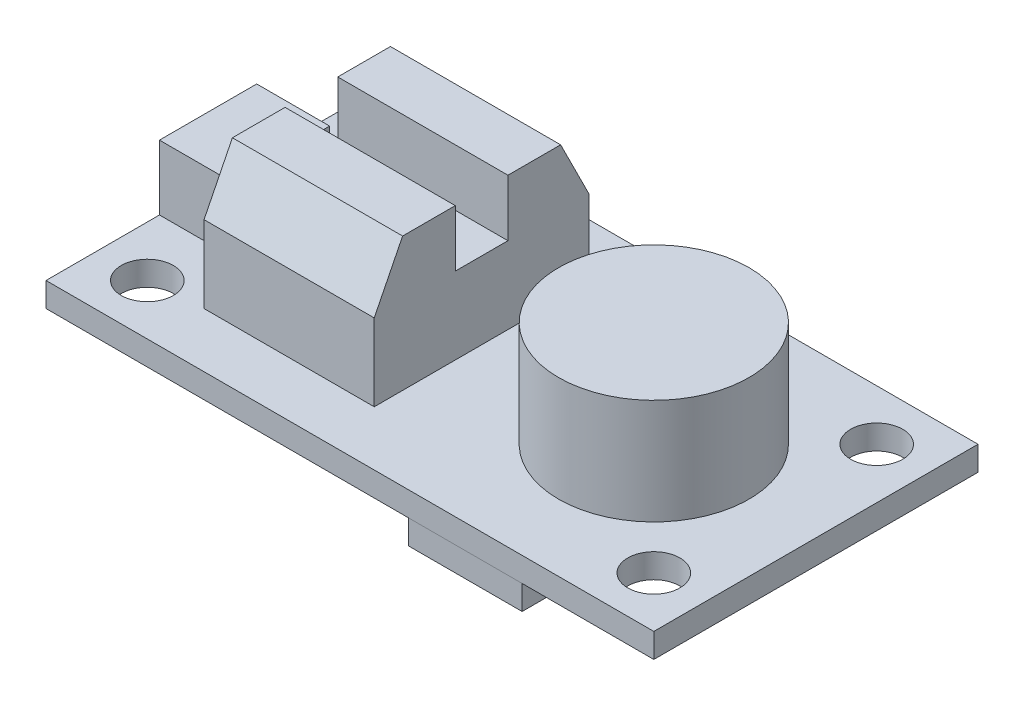
from build123d import *

# Parameters (mm, degrees)
SKETCH1_W               = 38.1
SKETCH1_H               = 20.32
BOSS_EXTRUDE1_DEPTH     = 1.524
F_4_CLEARANCE_HOLE1_D   = 3.2639
SKETCH4_W               = 4.572
SKETCH4_H               = 6.096
BOSS_EXTRUDE2_DEPTH     = 4.064
SKETCH5_R               = 5.969
BOSS_EXTRUDE3_DEPTH     = 6.604
SKETCH6_W               = 10.668
SKETCH6_H               = 13.462
BOSS_EXTRUDE4_DEPTH     = 4.826
BOSS_EXTRUDE5_DEPTH     = 10.668
SKETCH8_W               = 7.874
SKETCH8_H               = 5.588
BOSS_EXTRUDE6_DEPTH     = 3.048
SKETCH9_W               = 7.112
SKETCH9_H               = 5.08
BOSS_EXTRUDE7_DEPTH     = 1.524
SKETCH10_W              = 2.54
SKETCH10_H              = 4.064
BOSS_EXTRUDE8_DEPTH     = 1.016
SKETCH11_W              = 5.08
SKETCH11_H              = 5.08
BOSS_EXTRUDE9_DEPTH     = 1.016
SKETCH12_W              = 4.064
SKETCH12_H              = 2.032
BOSS_EXTRUDE10_DEPTH    = 1.016
SKETCH13_W              = 3.048
SKETCH13_H              = 3.048
BOSS_EXTRUDE11_DEPTH    = 0.508
SKETCH14_W              = 3.048
SKETCH14_H              = 3.556
BOSS_EXTRUDE12_DEPTH    = 1.016
SKETCH15_W              = 2.032
SKETCH15_H              = 4.064
BOSS_EXTRUDE13_DEPTH    = 1.524
SKETCH16_W              = 3.048
SKETCH16_H              = 3.048
BOSS_EXTRUDE14_DEPTH    = 1.016
SKETCH17_R              = 0.508
BOSS_EXTRUDE15_DEPTH    = 1.524
LPATTERN1_COUNT         = 4
LPATTERN1_PITCH         = 2.794
MIRROR1_COPY_1_SKETCH_R = 0.508
MIRROR1_COPY_1_DEPTH    = 1.524
MIRROR1_COPY_2_SKETCH_R = 0.508
MIRROR1_COPY_2_DEPTH    = 1.524
MIRROR1_COPY_3_SKETCH_R = 0.508
MIRROR1_COPY_3_DEPTH    = 1.524


with BuildPart() as part:
    # Sketch1 → Boss-Extrude1 (new body)
    with BuildSketch(Plane(origin=(0, 0, 0), x_dir=(1, 0, 0), z_dir=(0, 1, 0))):
        Rectangle(SKETCH1_W, SKETCH1_H)
    extrude(amount=BOSS_EXTRUDE1_DEPTH)

    # #4 Clearance Hole1 (through all)
    with Locations(Plane(origin=(0, 1.524, 0), x_dir=(1, 0, 0), z_dir=(0, 1, 0))):
        with Locations((-15.875, 6.985), (15.875, -6.985), (-15.875, -6.985), (15.875, 6.985)):
            Hole(F_4_CLEARANCE_HOLE1_D / 2)

    # Sketch4 → Boss-Extrude2 (add)
    with BuildSketch(Plane(origin=(0, 1.524, 0), x_dir=(1, 0, 0), z_dir=(0, 1, 0))):
        with Locations((-16.764, 0)):
            Rectangle(SKETCH4_W, SKETCH4_H)
    extrude(amount=BOSS_EXTRUDE2_DEPTH)

    # Sketch5 → Boss-Extrude3 (add)
    with BuildSketch(Plane(origin=(0, 1.524, 0), x_dir=(1, 0, 0), z_dir=(0, 1, 0))):
        with Locations((8.89, 0)):
            Circle(SKETCH5_R)
    extrude(amount=BOSS_EXTRUDE3_DEPTH)

    # Sketch6 → Boss-Extrude4 (add)
    with BuildSketch(Plane(origin=(0, 1.524, 0), x_dir=(1, 0, 0), z_dir=(0, 1, 0))):
        with Locations((-7.239, 0)):
            Rectangle(SKETCH6_W, SKETCH6_H)
    extrude(amount=BOSS_EXTRUDE4_DEPTH)

    # Sketch7 → Boss-Extrude5 (add)
    with BuildSketch(Plane.ZY.offset(12.573)):
        Polygon((-6.731, 6.35), (-4.953, 9.906), (-1.651, 9.906), (-1.651, 6.35), align=None)
        Polygon((6.731, 6.35), (4.953, 9.906), (1.651, 9.906), (1.651, 6.35), align=None)
    extrude(amount=-BOSS_EXTRUDE5_DEPTH)

    # Sketch8 → Boss-Extrude6 (add)
    with BuildSketch(Plane.XZ):
        with Locations((7.239, -7.366)):
            Rectangle(SKETCH8_W, SKETCH8_H)
    extrude(amount=BOSS_EXTRUDE6_DEPTH)

    # Sketch9 → Boss-Extrude7 (add)
    with BuildSketch(Plane.XZ):
        with Locations((7.239, 7.62)):
            Rectangle(SKETCH9_W, SKETCH9_H)
    extrude(amount=BOSS_EXTRUDE7_DEPTH)

    # Sketch10 → Boss-Extrude8 (add)
    with BuildSketch(Plane.XZ):
        with Locations((13.589, 0)):
            Rectangle(SKETCH10_W, SKETCH10_H)
    extrude(amount=BOSS_EXTRUDE8_DEPTH)

    # Sketch11 → Boss-Extrude9 (add)
    with BuildSketch(Plane.XZ):
        with Locations((4.191, 0)):
            Rectangle(SKETCH11_W, SKETCH11_H)
    extrude(amount=BOSS_EXTRUDE9_DEPTH)

    # Sketch12 → Boss-Extrude10 (add)
    with BuildSketch(Plane.XZ):
        with Locations((-2.413, 7.112)):
            Rectangle(SKETCH12_W, SKETCH12_H)
    extrude(amount=BOSS_EXTRUDE10_DEPTH)

    # Sketch13 → Boss-Extrude11 (add)
    with BuildSketch(Plane.XZ):
        with Locations((-3.81, -6.096)):
            Rectangle(SKETCH13_W, SKETCH13_H)
    extrude(amount=BOSS_EXTRUDE11_DEPTH)

    # Sketch14 → Boss-Extrude12 (add)
    with BuildSketch(Plane.XZ):
        with Locations((-9.906, -6.35)):
            Rectangle(SKETCH14_W, SKETCH14_H)
    extrude(amount=BOSS_EXTRUDE12_DEPTH)

    # Sketch15 → Boss-Extrude13 (add)
    with BuildSketch(Plane.XZ):
        with Locations((-15.494, 1.27)):
            Rectangle(SKETCH15_W, SKETCH15_H)
    extrude(amount=BOSS_EXTRUDE13_DEPTH)

    # Sketch16 → Boss-Extrude14 (add)
    with BuildSketch(Plane.XZ):
        with Locations((-9.398, 0)):
            Rectangle(SKETCH16_W, SKETCH16_H)
    extrude(amount=BOSS_EXTRUDE14_DEPTH)

    # Sketch17 → Boss-Extrude15 (add)
    with BuildSketch(Plane.XZ):
        with Locations((-11.684, -3.556)):
            Circle(SKETCH17_R)
    boss_extrude15 = extrude(amount=BOSS_EXTRUDE15_DEPTH)

    # LPattern1: Boss-Extrude15 ×4
    with Locations(*[(i * LPATTERN1_PITCH, 0, 0) for i in range(1, LPATTERN1_COUNT)]):
        add(boss_extrude15)

    # Mirror1: Boss-Extrude15 across plane
    add(boss_extrude15.mirror(Plane.XY))

    # Mirror1 copy 1 sketch → Mirror1 copy 1 (add)
    with BuildSketch(Plane(origin=(2.794, 0, 0), x_dir=(1, 0, 0), z_dir=(0, -1, 0))):
        with Locations((-11.684, 3.556)):
            Circle(MIRROR1_COPY_1_SKETCH_R)
    extrude(amount=MIRROR1_COPY_1_DEPTH)

    # Mirror1 copy 2 sketch → Mirror1 copy 2 (add)
    with BuildSketch(Plane(origin=(5.588, 0, 0), x_dir=(1, 0, 0), z_dir=(0, -1, 0))):
        with Locations((-11.684, 3.556)):
            Circle(MIRROR1_COPY_2_SKETCH_R)
    extrude(amount=MIRROR1_COPY_2_DEPTH)

    # Mirror1 copy 3 sketch → Mirror1 copy 3 (add)
    with BuildSketch(Plane(origin=(8.382, 0, 0), x_dir=(1, 0, 0), z_dir=(0, -1, 0))):
        with Locations((-11.684, 3.556)):
            Circle(MIRROR1_COPY_3_SKETCH_R)
    extrude(amount=MIRROR1_COPY_3_DEPTH)


solid = part.part
